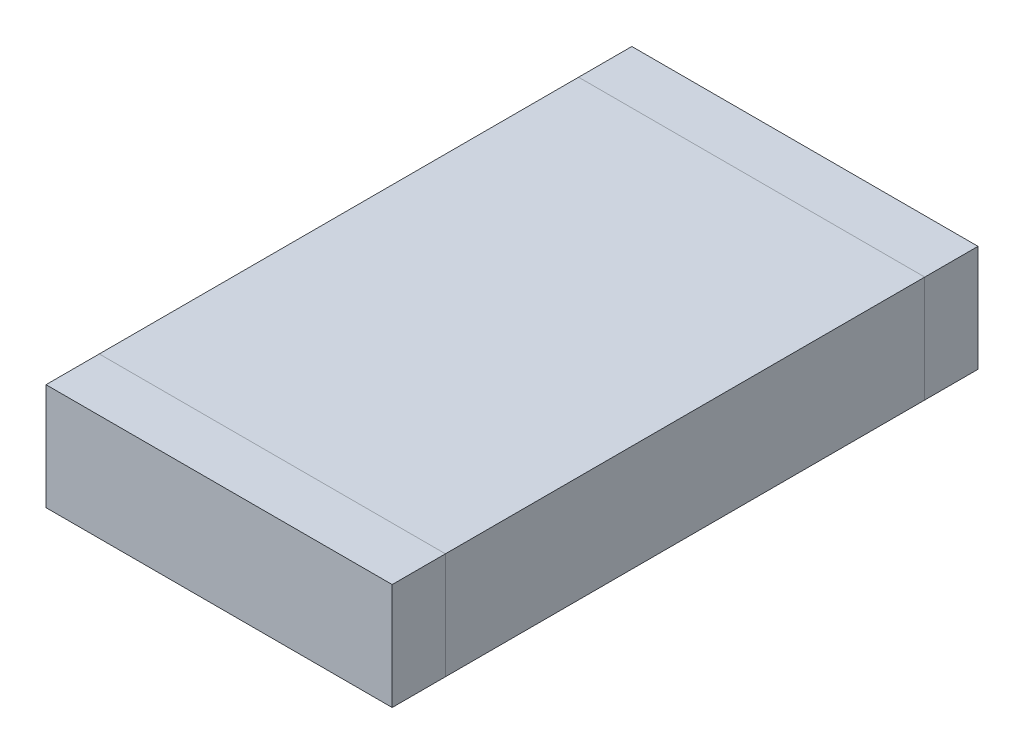
from build123d import *

# Parameters (mm, degrees)
SKETCH1_W  = 1.3
SKETCH1_H  = 1.8
MB_DEPTH   = 0.4
SKETCH2_W  = 1.3
SKETCH2_H  = 0.4
SB_L_DEPTH = 0.2
SKETCH3_W  = 1.3
SKETCH3_H  = 0.4
SB_R_DEPTH = 0.2


with BuildPart() as part:
    # Sketch1 → MB (new body)
    with BuildSketch(Plane(origin=(0, 0, 0), x_dir=(1, 0, 0), z_dir=(0, 1, 0))):
        Rectangle(SKETCH1_W, SKETCH1_H)
    extrude(amount=MB_DEPTH)


with BuildPart() as body_2:
    # Sketch2 → SB L (new body)
    with BuildSketch(Plane.XY.offset(0.9)):
        with Locations((0, 0.2)):
            Rectangle(SKETCH2_W, SKETCH2_H)
    extrude(amount=SB_L_DEPTH)


with BuildPart() as body_3:
    # Sketch3 → SB R (new body)
    with BuildSketch(Plane(origin=(0, 0, -0.9), x_dir=(-1, 0, 0), z_dir=(0, 0, -1))):
        with Locations((0, 0.2)):
            Rectangle(SKETCH3_W, SKETCH3_H)
    extrude(amount=SB_R_DEPTH)


solid = Compound([part.part, body_2.part, body_3.part])
